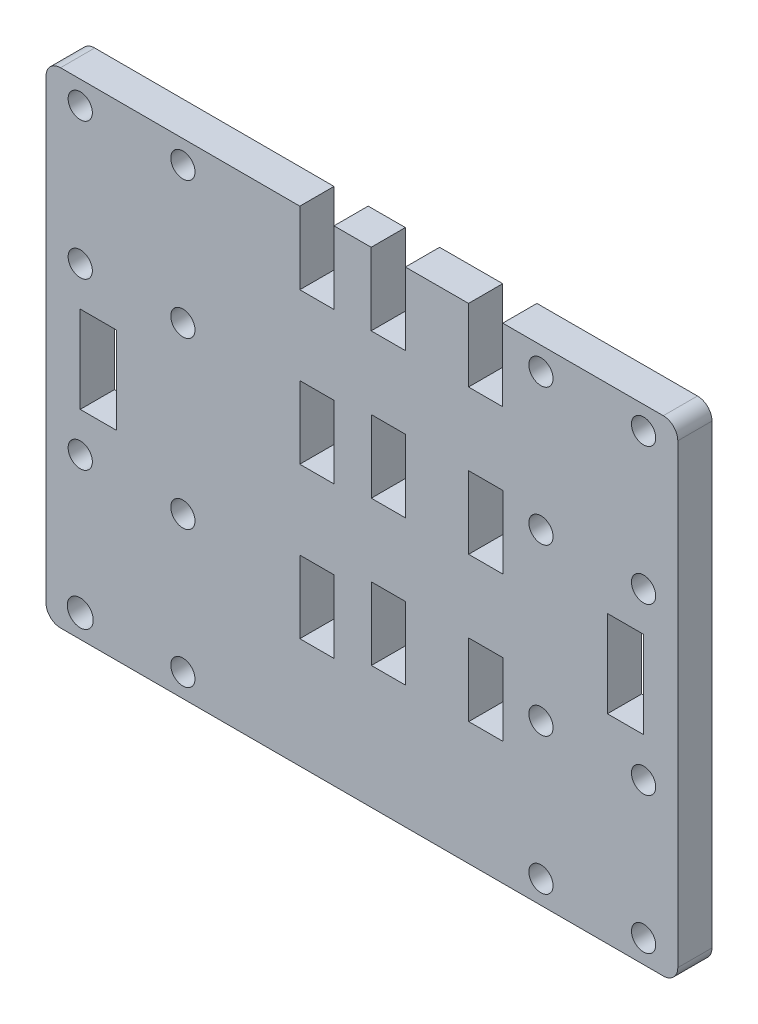
from build123d import *

# Parameters (mm, degrees)
SKETCH1_R           = 2.281562065
SKETCH1_R_2         = 2.125
SKETCH1_W           = 5.9944
SKETCH1_H           = 12.7
SKETCH1_W_2         = 5.986441201
SKETCH1_H_2         = 12.703753504
SKETCH1_W_3         = 5.986441202
BOSS_EXTRUDE1_DEPTH = 5.9944


with BuildPart() as part:
    # Sketch1 → Boss-Extrude1 (new body)
    with BuildSketch(Plane.XY):
        with BuildLine():
            Line((270.254984812, 144.069366267), (333.659384812, 144.069366267))
            Line((333.659384812, 144.069366267), (339.653784812, 144.069366267))
            Line((339.653784812, 144.069366267), (375.974984812, 144.069366267))
            ThreePointArc((375.974984812, 144.069366267), (377.771036036, 144.813315043), (378.514984812, 146.609366267))
            Line((378.514984812, 146.609366267), (378.514984812, 226.632730682))
            ThreePointArc((378.514984812, 226.632730682), (377.770473259, 228.429344507), (375.973393287, 229.172730183))
            Line((375.973393287, 229.172730183), (347.813544609, 229.155085658))
            Line((347.813544609, 229.155085658), (347.813544609, 216.451324674))
            Line((347.813544609, 216.451324674), (341.815166975, 216.451324674))
            Line((341.815166975, 216.451324674), (341.815166975, 229.155085658))
            Line((341.815166975, 229.155085658), (330.740769149, 229.140627138))
            Line((330.740769149, 229.140627138), (330.740769149, 216.444385628))
            Line((330.740769149, 216.444385628), (324.738412704, 216.444385628))
            Line((324.738412704, 216.444385628), (324.738412704, 229.140627138))
            Line((324.738412704, 229.140627138), (318.219144609, 229.136542265))
            Line((318.219144609, 229.136542265), (318.219144609, 216.431429486))
            Line((318.219144609, 216.431429486), (312.224744609, 216.431429486))
            Line((312.224744609, 216.431429486), (312.224744609, 229.131429486))
            Line((312.224744609, 229.131429486), (270.25739927, 229.171322574))
            ThreePointArc((270.25739927, 229.171322574), (268.45978743, 228.428228383), (267.714984812, 226.631323721))
            Line((267.714984812, 226.631323721), (267.714984812, 146.609366267))
            ThreePointArc((267.714984812, 146.609366267), (268.458933587, 144.813315043), (270.254984812, 144.069366267))
        make_face()
        with Locations((273.714984812, 148.112259486)):
            Circle(SKETCH1_R, mode=Mode.SUBTRACT)
        with Locations((291.714984812, 148.112259486)):
            Circle(SKETCH1_R_2, mode=Mode.SUBTRACT)
        with Locations((273.714984812, 172.112259486)):
            Circle(SKETCH1_R_2, mode=Mode.SUBTRACT)
        with Locations((291.714984812, 172.112259486)):
            Circle(SKETCH1_R_2, mode=Mode.SUBTRACT)
        Polygon((273.709384812, 179.000344994), (273.709384812, 186.620344994), (273.709384812, 194.240344994), (280.059384812, 194.240344994), (280.059384812, 179.000344994), align=None, mode=Mode.SUBTRACT)
        with Locations((315.221944609, 169.781429486)):
            Rectangle(SKETCH1_W, SKETCH1_H, mode=Mode.SUBTRACT)
        with Locations((354.514984812, 148.112259486)):
            Circle(SKETCH1_R_2, mode=Mode.SUBTRACT)
        with Locations((372.514984812, 148.112259486)):
            Circle(SKETCH1_R_2, mode=Mode.SUBTRACT)
        with Locations((327.771421413, 171.992516355)):
            Rectangle(SKETCH1_W_2, SKETCH1_H_2, mode=Mode.SUBTRACT)
        with Locations((344.840218063, 172.003211399)):
            Rectangle(SKETCH1_W_3, SKETCH1_H_2, mode=Mode.SUBTRACT)
        with Locations((354.514984812, 172.112259486)):
            Circle(SKETCH1_R_2, mode=Mode.SUBTRACT)
        with Locations((372.514984812, 172.112259486)):
            Circle(SKETCH1_R_2, mode=Mode.SUBTRACT)
        Polygon((372.520584812, 186.620344994), (372.520584812, 179.000344994), (366.170584812, 179.000344994), (366.170584812, 194.240344994), (372.520584812, 194.240344994), align=None, mode=Mode.SUBTRACT)
        with Locations((273.714984812, 201.131429486)):
            Circle(SKETCH1_R_2, mode=Mode.SUBTRACT)
        with Locations((291.714984812, 201.131429486)):
            Circle(SKETCH1_R_2, mode=Mode.SUBTRACT)
        with Locations((315.221944609, 196.281429486)):
            Rectangle(SKETCH1_W, SKETCH1_H, mode=Mode.SUBTRACT)
        with Locations((273.714984812, 225.131429486)):
            Circle(SKETCH1_R_2, mode=Mode.SUBTRACT)
        with Locations((291.714984812, 225.131429486)):
            Circle(SKETCH1_R_2, mode=Mode.SUBTRACT)
        with Locations((327.75550617, 197.392511369)):
            Rectangle(SKETCH1_W_3, SKETCH1_H_2, mode=Mode.SUBTRACT)
        with Locations((344.82430282, 197.403206413)):
            Rectangle(SKETCH1_W_2, SKETCH1_H_2, mode=Mode.SUBTRACT)
        with Locations((354.514984812, 201.131429486)):
            Circle(SKETCH1_R_2, mode=Mode.SUBTRACT)
        with Locations((372.514984812, 201.131429486)):
            Circle(SKETCH1_R_2, mode=Mode.SUBTRACT)
        with Locations((354.514984812, 225.131429486)):
            Circle(SKETCH1_R_2, mode=Mode.SUBTRACT)
        with Locations((372.514984812, 225.131429486)):
            Circle(SKETCH1_R_2, mode=Mode.SUBTRACT)
    extrude(amount=BOSS_EXTRUDE1_DEPTH)


solid = part.part
